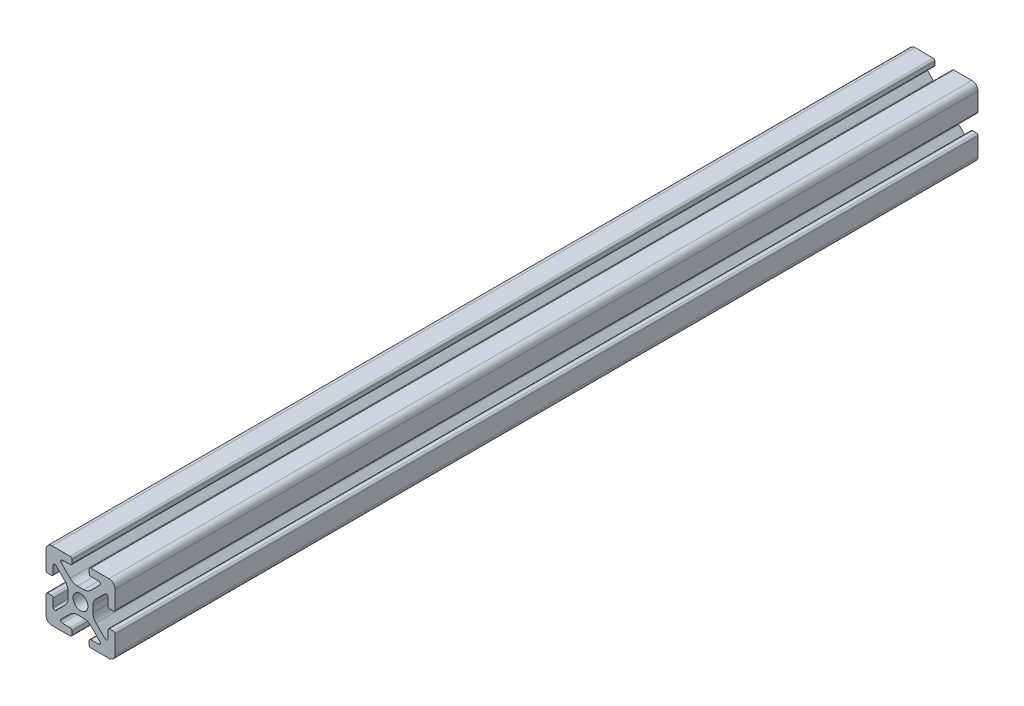
from build123d import *

# Parameters (mm, degrees)
BOSS_EXTRUDE1_DEPTH = 125


with BuildPart() as part:
    # Sketch4 → Boss-Extrude1 (new body, symmetric)
    with BuildSketch(Plane.XY):
        with BuildLine():
            Line((3, -10), (8.25, -10))
            ThreePointArc((8.25, -10), (9.487436867, -9.487436867), (10, -8.25))
            Line((10, -8.25), (10, -3))
            ThreePointArc((10, -3), (9.853553391, -2.646446609), (9.5, -2.5))
            Line((9.5, -2.5), (8.424621202, -2.5))
            ThreePointArc((8.424621202, -2.5), (8.071067812, -2.646446609), (7.924621202, -3))
            Line((7.924621202, -3), (7.924621202, -5.25))
            ThreePointArc((7.924621202, -5.25), (7.615962919, -5.711939766), (7.071067812, -5.603553391))
            Line((7.071067812, -5.603553391), (4.478679656, -3.011165235))
            ThreePointArc((4.478679656, -3.011165235), (3.828361402, -2.037895189), (3.6, -0.889844892))
            Line((3.6, -0.889844892), (3.6, 0))
            Line((3.6, 0), (2.15, 0))
            ThreePointArc((2.15, 0), (1.52027958, -1.52027958), (0, -2.15))
            Line((0, -2.15), (0, -3.6))
            Line((0, -3.6), (0.889844892, -3.6))
            ThreePointArc((0.889844892, -3.6), (2.037895189, -3.828361402), (3.011165235, -4.478679656))
            Line((3.011165235, -4.478679656), (5.603553391, -7.071067812))
            ThreePointArc((5.603553391, -7.071067812), (5.711939766, -7.615962919), (5.25, -7.924621202))
            Line((5.25, -7.924621202), (3, -7.924621202))
            ThreePointArc((3, -7.924621202), (2.646446609, -8.071067812), (2.5, -8.424621202))
            Line((2.5, -8.424621202), (2.5, -9.5))
            ThreePointArc((2.5, -9.5), (2.646446609, -9.853553391), (3, -10))
        make_face()
    extrude(amount=BOSS_EXTRUDE1_DEPTH, both=True)

    # Mirror1: part across plane


with BuildPart() as part_1:
    add(part.part)
    add(part.part.mirror(Plane(origin=(0, 0, 0), x_dir=(0, 0, 1), z_dir=(1, 0, 0))))

    # Mirror2: part across plane


with BuildPart() as part_2:
    add(part_1.part)
    add(part_1.part.mirror(Plane.ZX))


solid = part_2.part
